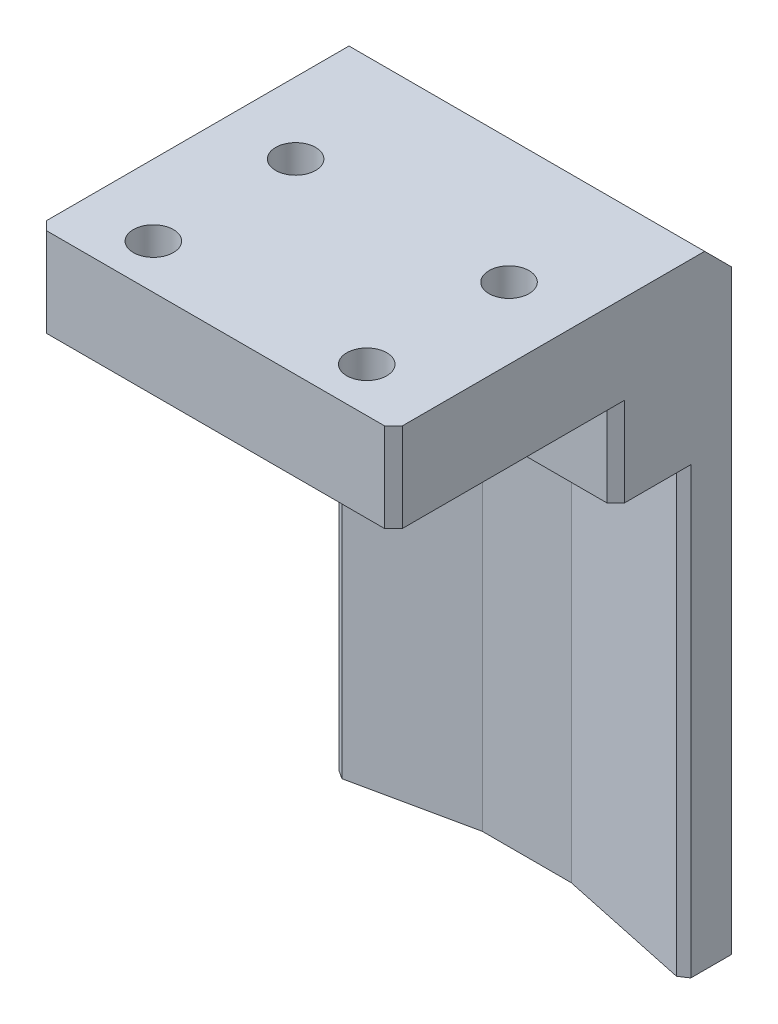
from build123d import *
from OCP.BRepFilletAPI import BRepFilletAPI_MakeChamfer

# Parameters (mm, degrees)
SKETCH_1_W                   = 40
SKETCH_1_H                   = 15
EXTRUDE_1_DEPTH              = 60
SKETCH_3_W                   = 40
SKETCH_3_H                   = 40
EXTRUDE_2_DEPTH              = 10
HOLE_WIZARD_M4_1_D           = 4.5
HOLE_WIZARD_M4_1_CBORE_D     = 8
HOLE_WIZARD_M4_1_CBORE_DEPTH = 4.4
CHAMFER_1_SIZE               = 5
CHAMFER_2_SIZE               = 2
CUT_EXTRUDE_2_DEPTH          = 50
CHAMFER_3_SIZE               = 1
CHAMFER_3_SIZE2              = 0.84312817
CUT_EXTRUDE_3_DEPTH          = 10
CHAMFER_4_SIZE               = 1


with BuildPart() as part:
    # 草图1 → 凸台-拉伸1 (new body)
    with BuildSketch(Plane(origin=(0, 0, 0), x_dir=(1, 0, 0), z_dir=(0, 1, 0))):
        Rectangle(SKETCH_1_W, SKETCH_1_H)
    extrude(amount=EXTRUDE_1_DEPTH)

    # 草图3 → 凸台-拉伸2 (add)
    with BuildSketch(Plane(origin=(0, 60, 0), x_dir=(1, 0, 0), z_dir=(0, 1, 0))):
        with Locations((0, -12.5)):
            Rectangle(SKETCH_3_W, SKETCH_3_H)
    extrude(amount=EXTRUDE_2_DEPTH)

    # M4 六角凹头螺钉的柱形沉头孔1 (through all)
    with Locations(Plane(origin=(0, 60, 0), x_dir=(-1, 0, 0), z_dir=(0, -1, 0))):
        with Locations((12, -11.5), (-12, -11.5), (12, -27.5), (-12, -27.5)):
            CounterBoreHole(HOLE_WIZARD_M4_1_D / 2, HOLE_WIZARD_M4_1_CBORE_D / 2, HOLE_WIZARD_M4_1_CBORE_DEPTH)

    # 倒角1
    chamfer_1_edges = [part.edges().sort_by_distance(p)[0] for p in [
        (0, 70, -7.5),
    ]]
    chamfer(chamfer_1_edges, length=CHAMFER_1_SIZE)

    # 倒角2
    chamfer_2_edges = [part.edges().sort_by_distance(p)[0] for p in [
        (-20, 32.5, -7.5),
        (20, 32.5, -7.5),
    ]]
    chamfer(chamfer_2_edges, length=CHAMFER_2_SIZE)

    # 草图7 → 切除-拉伸2 (cut)
    with BuildSketch(Plane.XZ):
        Polygon((-6, -3.5), (4, -3.5), (25.464703606, 1.062463596), (25.464703606, 11.878030996), (-23.00207338, 11.878030996), (-23.00207338, 0.113902259), align=None)
    extrude(amount=-CUT_EXTRUDE_2_DEPTH, mode=Mode.SUBTRACT)

    # 倒角3: one chamfer whose edges measure the first distance from different faces: ONE call of the kernel's chamfer builder (chamfer() names one face for all edges)
    chamfer_3_edges_1 = [part.edges().sort_by_distance(p)[0] for p in [
        (-20, 25, -0.524208137),
    ]]
    chamfer_3_side_1 = [part.faces().sort_by_distance(p)[0] for p in [
        (-13, 25, -2.012104068),
    ]]
    chamfer_3_edges_2 = [part.edges().sort_by_distance(p)[0] for p in [
        (20, 25, -0.099095013),
    ]]
    chamfer_3_side_2 = [part.faces().sort_by_distance(p)[0] for p in [
        (12, 25, -1.799547507),
    ]]
    chamfer_3 = BRepFilletAPI_MakeChamfer(part.part.solid().wrapped)
    for e in chamfer_3_edges_1:
        chamfer_3.Add(CHAMFER_3_SIZE, CHAMFER_3_SIZE2, e.wrapped, chamfer_3_side_1[0].wrapped)  # the first distance lies on this face
    for e in chamfer_3_edges_2:
        chamfer_3.Add(CHAMFER_3_SIZE, CHAMFER_3_SIZE2, e.wrapped, chamfer_3_side_2[0].wrapped)  # the first distance lies on this face
    add(Compound.cast(chamfer_3.Shape()), mode=Mode.REPLACE)

    # 草图8 → 切除-拉伸3 (cut)
    with BuildSketch(Plane.XZ.offset(-50)):
        Polygon((-10, 7.5), (-5, 2.5), (5, 2.5), (10, 7.5), align=None)
    extrude(amount=-CUT_EXTRUDE_3_DEPTH, mode=Mode.SUBTRACT)

    # 倒角4
    chamfer_4_edges = [part.edges().sort_by_distance(p)[0] for p in [
        (-20, 65, 32.5),
        (20, 65, 32.5),
        (-20, 55, 7.5),
        (20, 55, 7.5),
    ]]
    chamfer(chamfer_4_edges, length=CHAMFER_4_SIZE)


solid = part.part
